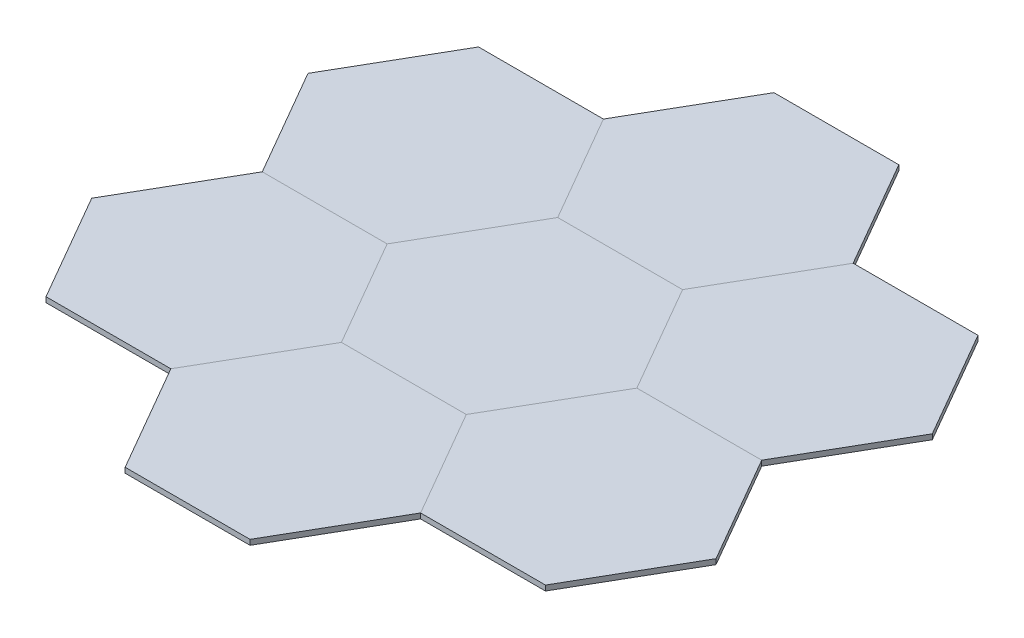
from build123d import *

# Parameters (mm, degrees)
BOSS_EXTRUDE1_DEPTH = 3.175
CIRPATTERN1_COUNT   = 6


with BuildPart() as part:
    # Sketch1 → Boss-Extrude1 (new body)
    with BuildSketch(Plane(origin=(0, 0, 0), x_dir=(1, 0, 0), z_dir=(0, 1, 0))):
        Polygon((76.2, 0), (38.1, 65.991135768), (-38.1, 65.991135768), (-76.2, 0), (-38.1, -65.991135768), (38.1, -65.991135768), align=None)
    extrude(amount=BOSS_EXTRUDE1_DEPTH)


with BuildPart() as body_2:
    # Mirror1: mirrored copy
    add(part.part.mirror(Plane(origin=(38.1, 3.175, 65.991135768), x_dir=(-0.4999999999999949, 0, 0.8660254037844416), z_dir=(-0.8660254037844416, 0, -0.4999999999999949))))


with BuildPart() as cirpattern1_1:
    # CirPattern1: pattern copy
    add(body_2.part.rotate(Axis((0, 0, 0), (0, 1, 0)), 1 * 360 / CIRPATTERN1_COUNT))


with BuildPart() as cirpattern1_2:
    # CirPattern1: pattern copy
    add(body_2.part.rotate(Axis((0, 0, 0), (0, 1, 0)), 2 * 360 / CIRPATTERN1_COUNT))


with BuildPart() as cirpattern1_3:
    # CirPattern1: pattern copy
    add(body_2.part.rotate(Axis((0, 0, 0), (0, 1, 0)), 3 * 360 / CIRPATTERN1_COUNT))


with BuildPart() as cirpattern1_4:
    # CirPattern1: pattern copy
    add(body_2.part.rotate(Axis((0, 0, 0), (0, 1, 0)), 4 * 360 / CIRPATTERN1_COUNT))


with BuildPart() as cirpattern1_5:
    # CirPattern1: pattern copy
    add(body_2.part.rotate(Axis((0, 0, 0), (0, 1, 0)), 5 * 360 / CIRPATTERN1_COUNT))


solid = Compound([part.part, body_2.part, cirpattern1_1.part, cirpattern1_2.part, cirpattern1_3.part, cirpattern1_4.part, cirpattern1_5.part])
